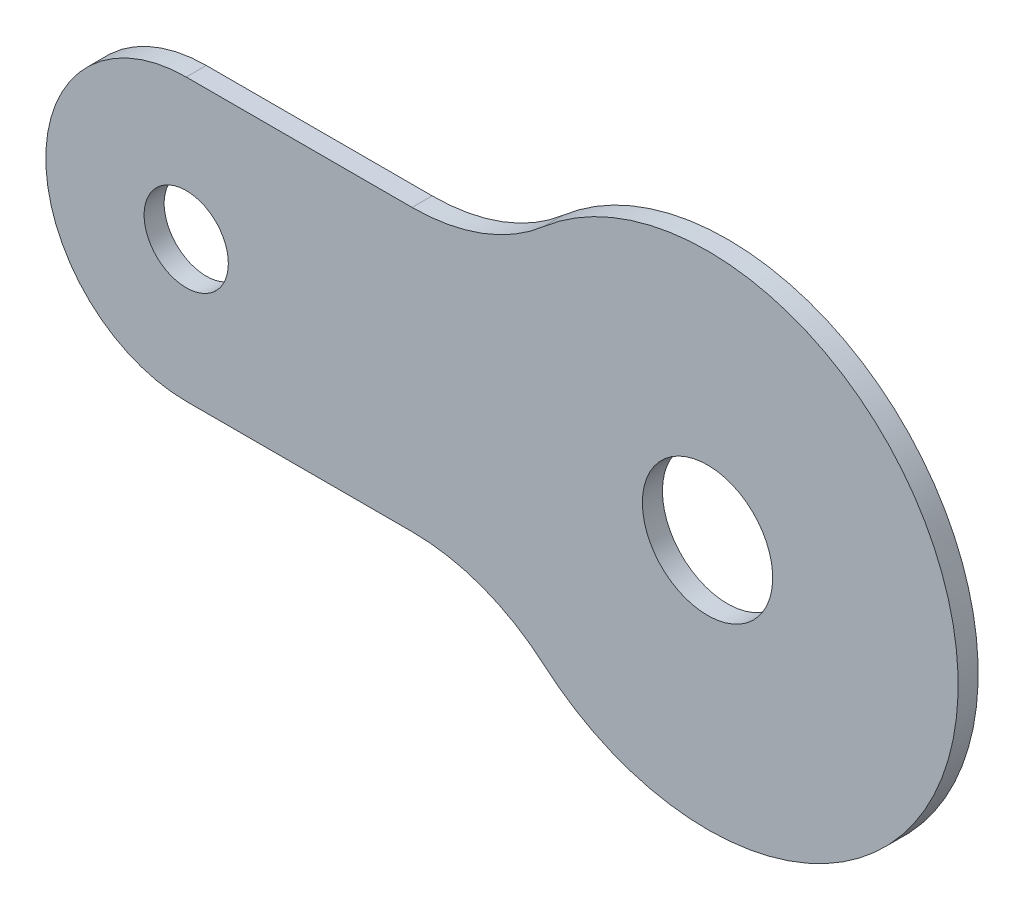
from build123d import *

# Parameters (mm, degrees)
ESQUISSE1_R                               = 12.5
BOSS_EXTRU_1_DEPTH                        = 1
BOSS_EXTRU_2_DEPTH                        = 1
TROU_POUR_TARAUDAGE_POUR_TROU_TARAUD_M5_D = 4.2
ESQUISSE8_R                               = 3.25
ENL_V_MAT_EXTRU_1_DEPTH                   = 2
CONG_1_R                                  = 10


with BuildPart() as part:
    # Esquisse1 → Boss.-Extru.1 (new body)
    with BuildSketch(Plane.XY):
        Circle(ESQUISSE1_R)
    extrude(amount=BOSS_EXTRU_1_DEPTH)

    # Esquisse4 → Boss.-Extru.2 (add)
    with BuildSketch(Plane.XY.offset(1)):
        with BuildLine():
            Line((-26, 7.00382031), (-10.353574313, 7.00382031))
            ThreePointArc((-10.353574313, 7.00382031), (-12.5, 0), (-10.353574313, -7.00382031))
            Line((-10.353574313, -7.00382031), (-26, -7.00382031))
            ThreePointArc((-26, -7.00382031), (-33.00382031, 0), (-26, 7.00382031))
        make_face()
    extrude(amount=-BOSS_EXTRU_2_DEPTH)

    # Trou pour taraudage pour trou taraudé M52 (through all)
    with Locations(Plane.XY.offset(1)):
        with Locations((-26, 0)):
            Hole(TROU_POUR_TARAUDAGE_POUR_TROU_TARAUD_M5_D / 2)

    # Esquisse8 → Enlèv. mat.-Extru.1 (cut, through all)
    with BuildSketch(Plane(origin=(0, 0, 0), x_dir=(-1, 0, 0), z_dir=(0, 0, -1))):
        Circle(ESQUISSE8_R)
    extrude(amount=-ENL_V_MAT_EXTRU_1_DEPTH, mode=Mode.SUBTRACT)

    # Congé1
    cong_1_edges = [part.edges().sort_by_distance(p)[0] for p in [
        (-10.353574313, 7.00382031, 0.5),
        (-10.353574313, -7.00382031, 0.5),
    ]]
    fillet(cong_1_edges, radius=CONG_1_R)


solid = part.part
